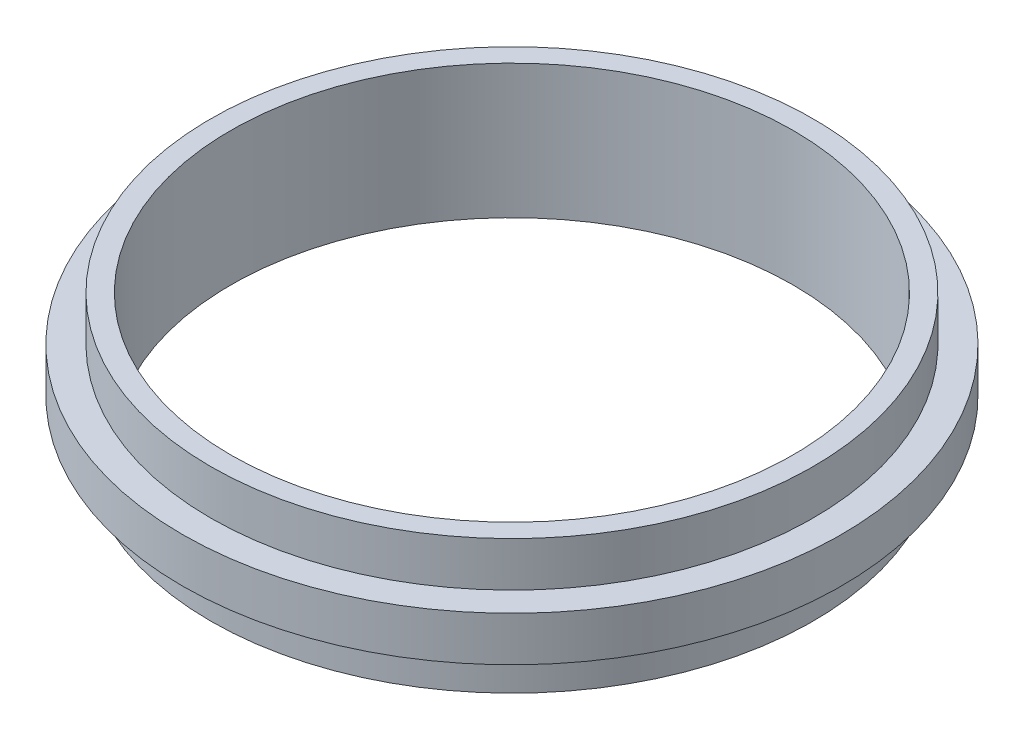
from build123d import *

# Parameters (mm, degrees)
SKETCH1_R           = 93.7895
SKETCH1_R_2         = 80.01
BOSS_EXTRUDE1_DEPTH = 6.35
SKETCH3_R           = 85.725
SKETCH3_R_2         = 80.01
BOSS_EXTRUDE2_DEPTH = 12.7


with BuildPart() as part:
    # Sketch1 → Boss-Extrude1 (new body, symmetric)
    with BuildSketch(Plane(origin=(0, 0, 0), x_dir=(1, 0, 0), z_dir=(0, 1, 0))):
        Circle(SKETCH1_R)
        Circle(SKETCH1_R_2, mode=Mode.SUBTRACT)
    extrude(amount=BOSS_EXTRUDE1_DEPTH, both=True)

    # Sketch3 → Boss-Extrude2 (add)
    with BuildSketch(Plane(origin=(0, 6.35, 0), x_dir=(1, 0, 0), z_dir=(0, 1, 0))):
        Circle(SKETCH3_R)
        Circle(SKETCH3_R_2, mode=Mode.SUBTRACT)
    boss_extrude2 = extrude(amount=BOSS_EXTRUDE2_DEPTH)

    # Mirror2: Boss-Extrude2 across plane
    add(boss_extrude2.mirror(Plane.ZX))


solid = part.part
